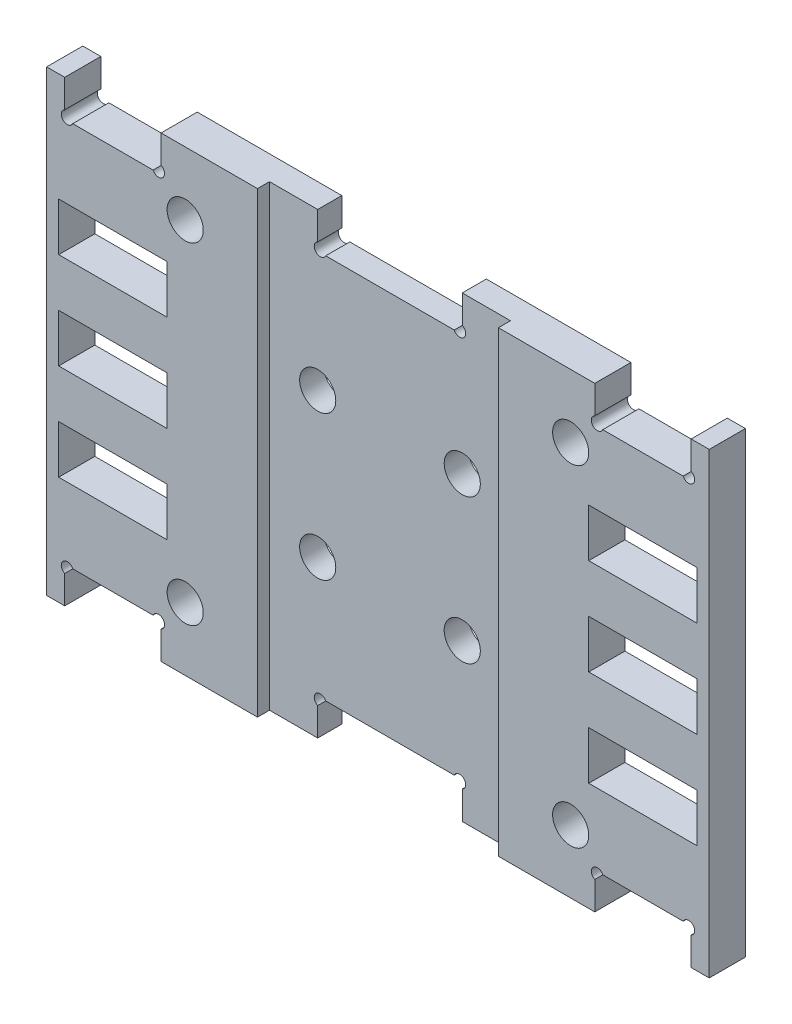
from build123d import *

# Parameters (mm, degrees)
SKETCH_1_W          = 55
SKETCH_1_H          = 38
EXTRUDE_1_DEPTH     = 3
SKETCH_2_R          = 1.5
CUT_EXTRUDE_1_DEPTH = 30
SKETCH_3_W          = 8
SKETCH_3_H          = 3
CUT_EXTRUDE_2_DEPTH = 30
SKETCH_4_W          = 20
SKETCH_4_H          = 38
CUT_EXTRUDE_3_DEPTH = 1
SKETCH_5_W          = 9
SKETCH_5_H          = 4
CUT_EXTRUDE_4_DEPTH = 10
SKETCH_6_W          = 12
SKETCH_6_H          = 3
CUT_EXTRUDE_5_DEPTH = 10
SKETCH_8_R          = 1.5
CUT_EXTRUDE_6_DEPTH = 10
SKETCH_9_R          = 0.5
CUT_EXTRUDE_7_DEPTH = 4


with BuildPart() as part:
    # 草图1 → 凸台-拉伸1 (new body)
    with BuildSketch(Plane.XY):
        Rectangle(SKETCH_1_W, SKETCH_1_H)
    extrude(amount=EXTRUDE_1_DEPTH)

    # 草图2 → 切除-拉伸1 (cut)
    with BuildSketch(Plane.XY.offset(3)):
        with Locations((16, 13.75)):
            Circle(SKETCH_2_R)
        with Locations((16, -13.75)):
            Circle(SKETCH_2_R)
        with Locations((-16, 13.75)):
            Circle(SKETCH_2_R)
        with Locations((-16, -13.75)):
            Circle(SKETCH_2_R)
    extrude(amount=-CUT_EXTRUDE_1_DEPTH, mode=Mode.SUBTRACT)

    # 草图3 → 切除-拉伸2 (cut)
    with BuildSketch(Plane.XY.offset(3)):
        with Locations((22, 17.5)):
            Rectangle(SKETCH_3_W, SKETCH_3_H)
        with Locations((22, -17.5)):
            Rectangle(SKETCH_3_W, SKETCH_3_H)
        with Locations((-22, 17.5)):
            Rectangle(SKETCH_3_W, SKETCH_3_H)
        with Locations((-22, -17.5)):
            Rectangle(SKETCH_3_W, SKETCH_3_H)
    extrude(amount=-CUT_EXTRUDE_2_DEPTH, mode=Mode.SUBTRACT)

    # 草图4 → 切除-拉伸3 (cut)
    with BuildSketch(Plane.XY.offset(3)):
        Rectangle(SKETCH_4_W, SKETCH_4_H)
    extrude(amount=-CUT_EXTRUDE_3_DEPTH, mode=Mode.SUBTRACT)

    # 草图5 → 切除-拉伸4 (cut)
    with BuildSketch(Plane.XY.offset(3)):
        with Locations((22, 8)):
            Rectangle(SKETCH_5_W, SKETCH_5_H)
        with Locations((22, 0)):
            Rectangle(SKETCH_5_W, SKETCH_5_H)
        with Locations((22, -8)):
            Rectangle(SKETCH_5_W, SKETCH_5_H)
        with Locations((-22, -8)):
            Rectangle(SKETCH_5_W, SKETCH_5_H)
        with Locations((-22, 8)):
            Rectangle(SKETCH_5_W, SKETCH_5_H)
        with Locations((-22, 0)):
            Rectangle(SKETCH_5_W, SKETCH_5_H)
    extrude(amount=-CUT_EXTRUDE_4_DEPTH, mode=Mode.SUBTRACT)

    # 草图6 → 切除-拉伸5 (cut)
    with BuildSketch(Plane.XY.offset(2)):
        with Locations((0, 17.5)):
            Rectangle(SKETCH_6_W, SKETCH_6_H)
        with Locations((0, -17.5)):
            Rectangle(SKETCH_6_W, SKETCH_6_H)
    extrude(amount=-CUT_EXTRUDE_5_DEPTH, mode=Mode.SUBTRACT)

    # 草图8 → 切除-拉伸6 (cut)
    with BuildSketch(Plane.XY.offset(2)):
        with Locations((6, -6)):
            Circle(SKETCH_8_R)
        with Locations((6, 6)):
            Circle(SKETCH_8_R)
        with Locations((-6, 6)):
            Circle(SKETCH_8_R)
        with Locations((-6, -6)):
            Circle(SKETCH_8_R)
    extrude(amount=-CUT_EXTRUDE_6_DEPTH, mode=Mode.SUBTRACT)

    # 草图9 → 切除-拉伸7 (cut, through all)
    with BuildSketch(Plane.XY.offset(3)):
        with Locations((25.787867966, -16.212132034)):
            Circle(SKETCH_9_R)
        with Locations((18.212132034, -16.212132034)):
            Circle(SKETCH_9_R)
        with Locations((18.212132034, 16.212132034)):
            Circle(SKETCH_9_R)
        with Locations((25.787867966, 16.212132034)):
            Circle(SKETCH_9_R)
        with Locations((-25.787867966, 16.212132034)):
            Circle(SKETCH_9_R)
        with Locations((-18.212132034, 16.212132034)):
            Circle(SKETCH_9_R)
        with Locations((-18.212132034, -16.212132034)):
            Circle(SKETCH_9_R)
        with Locations((-25.787867966, -16.212132034)):
            Circle(SKETCH_9_R)
        with Locations((5.787867966, -16.212132034)):
            Circle(SKETCH_9_R)
        with Locations((-5.787867966, -16.212132034)):
            Circle(SKETCH_9_R)
        with Locations((-5.787867966, 16.212132034)):
            Circle(SKETCH_9_R)
        with Locations((5.787867966, 16.212132034)):
            Circle(SKETCH_9_R)
    extrude(amount=-CUT_EXTRUDE_7_DEPTH, mode=Mode.SUBTRACT)


solid = part.part
